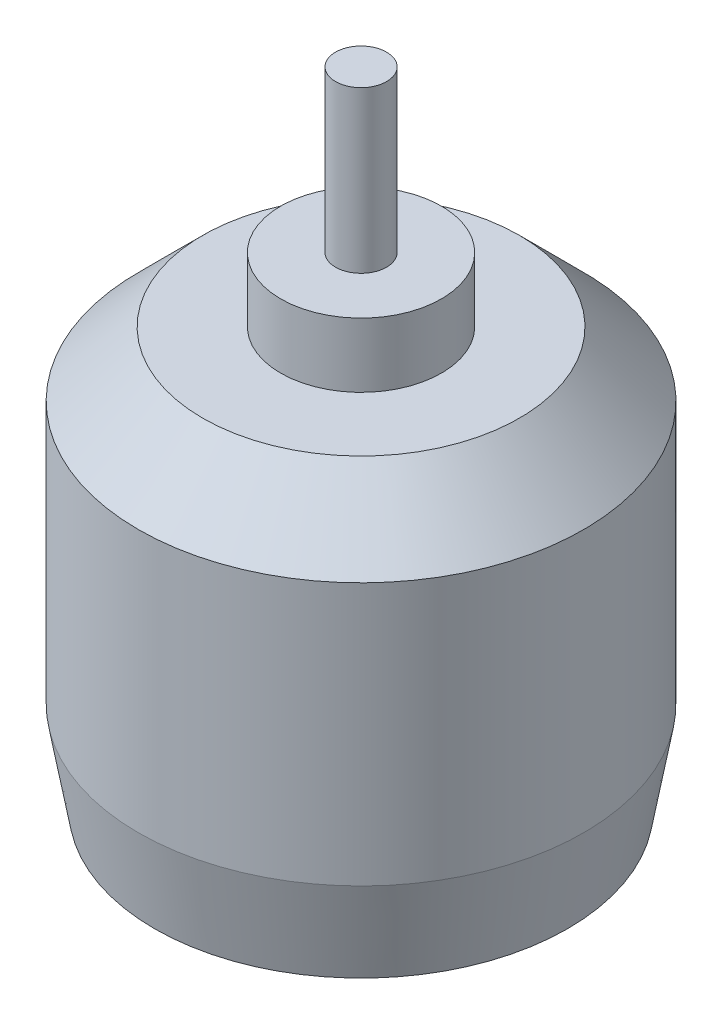
from build123d import *

# Parameters (mm, degrees)
CROQUIS1_R              = 13.85
SALIENTE_EXTRUIR1_DEPTH = 26
CHAFL_N1_SIZE           = 1
CHAFL_N1_SIZE2          = 5.67128182
CHAFL_N2_SIZE           = 4
CROQUIS3_R              = 5
SALIENTE_EXTRUIR3_DEPTH = 4
CROQUIS4_R              = 1.5875
SALIENTE_EXTRUIR4_DEPTH = 10
CROQUIS5_R              = 2.5
CORTAR_EXTRUIR1_DEPTH   = 4
CROQUIS6_R              = 4
CORTAR_EXTRUIR2_DEPTH   = 1.5


with BuildPart() as part:
    # Croquis1 → Saliente-Extruir1 (new body)
    with BuildSketch(Plane(origin=(0, 0, 0), x_dir=(1, 0, 0), z_dir=(0, 1, 0))):
        Circle(CROQUIS1_R)
    extrude(amount=SALIENTE_EXTRUIR1_DEPTH)

    # Chaflán1
    chafl_n1_edges = [part.edges().sort_by_distance(p)[0] for p in [
        (-13.85, 0, 0),
    ]]
    chafl_n1_side = [part.faces().sort_by_distance(p)[0] for p in [
        (0, 0, 0),
    ]]
    chamfer(chafl_n1_edges, length=CHAFL_N1_SIZE, length2=CHAFL_N1_SIZE2, reference=chafl_n1_side[0])

    # Chaflán2
    chafl_n2_edges = [part.edges().sort_by_distance(p)[0] for p in [
        (-13.85, 26, 0),
    ]]
    chamfer(chafl_n2_edges, length=CHAFL_N2_SIZE)

    # Croquis3 → Saliente-Extruir3 (add)
    with BuildSketch(Plane(origin=(0, 26, 0), x_dir=(1, 0, 0), z_dir=(0, 1, 0))):
        Circle(CROQUIS3_R)
    extrude(amount=SALIENTE_EXTRUIR3_DEPTH)

    # Croquis4 → Saliente-Extruir4 (add)
    with BuildSketch(Plane(origin=(0, 30, 0), x_dir=(1, 0, 0), z_dir=(0, 1, 0))):
        Circle(CROQUIS4_R)
    extrude(amount=SALIENTE_EXTRUIR4_DEPTH)

    # Croquis5 → Cortar-Extruir1 (cut)
    with BuildSketch(Plane.XZ):
        with Locations((8, 0)):
            Circle(CROQUIS5_R)
        with Locations((0, 9.5)):
            Circle(CROQUIS5_R)
        with Locations((0, -9.5)):
            Circle(CROQUIS5_R)
        with Locations((-8, 0)):
            Circle(CROQUIS5_R)
    extrude(amount=-CORTAR_EXTRUIR1_DEPTH, mode=Mode.SUBTRACT)

    # Croquis6 → Cortar-Extruir2 (cut)
    with BuildSketch(Plane.XZ):
        Circle(CROQUIS6_R)
    extrude(amount=-CORTAR_EXTRUIR2_DEPTH, mode=Mode.SUBTRACT)


solid = part.part
